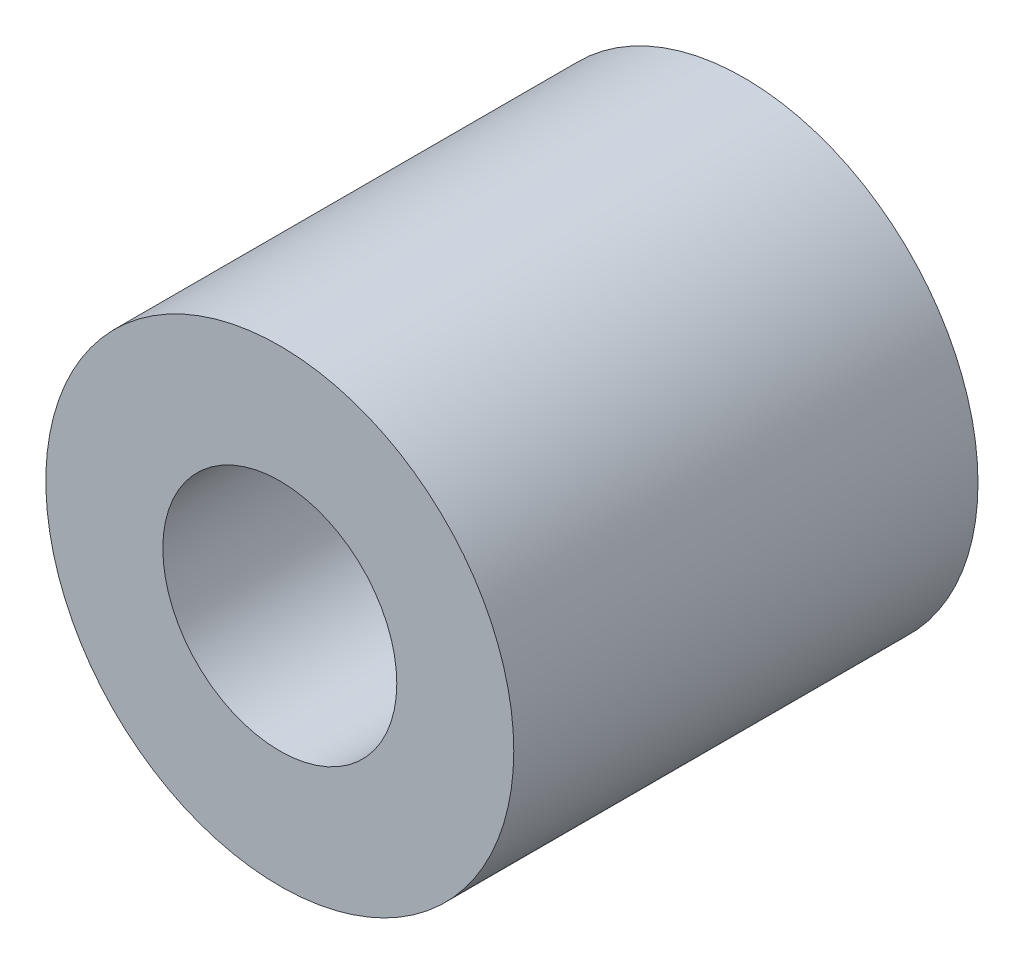
from build123d import *

# Parameters (mm, degrees)
SKETCH5_R                = 3.2004
SKETCH5_R_2              = 1.6002
BOSS_EXTRUDE1_DEPTH      = 3.175
BOSS_EXTRUDE1_DEPTH_BACK = 3.175


with BuildPart() as part:
    # Sketch5 → Boss-Extrude1 (new body, two sides)
    with BuildSketch(Plane.XY) as boss_extrude1_sk:
        Circle(SKETCH5_R)
        Circle(SKETCH5_R_2, mode=Mode.SUBTRACT)
    extrude(amount=BOSS_EXTRUDE1_DEPTH)
    extrude(boss_extrude1_sk.sketch, amount=-BOSS_EXTRUDE1_DEPTH_BACK)


solid = part.part
